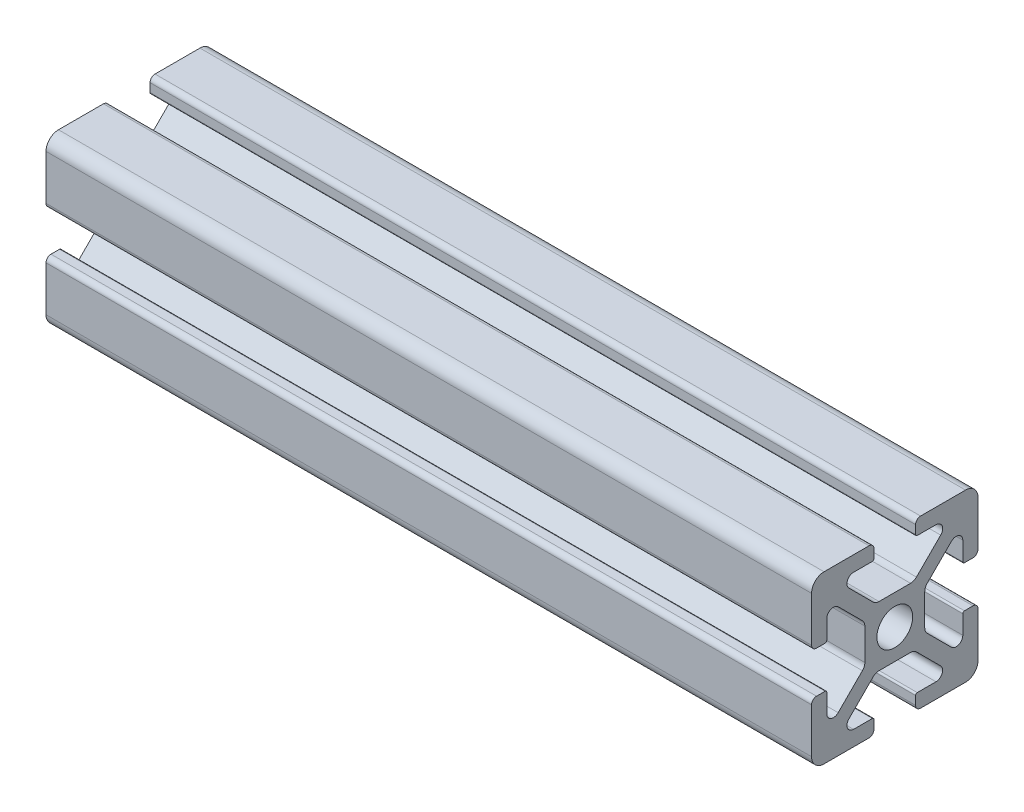
from build123d import *

# Parameters (mm, degrees)
BOSS_EXTRUDE1_DEPTH = 92


with BuildPart() as part:
    # Sketch3 → Boss-Extrude1 (new body)
    with BuildSketch(Plane(origin=(0, 0, 0), x_dir=(0, 0, -1), z_dir=(1, 0, 0))):
        with BuildLine():
            Line((-5.515685425, 6.807463915), (-2.601114729, 3.892893219))
            ThreePointArc((-2.601114729, 3.892893219), (-2.27669138, 3.676120467), (-1.894007948, 3.6))
            Line((-1.894007948, 3.6), (0, 3.6))
            Line((0, 3.6), (0, 2.15))
            ThreePointArc((0, 2.15), (-1.52027958, 1.52027958), (-2.15, 0))
            Line((-2.15, 0), (-3.6, 0))
            Line((-3.6, 0), (-3.6, 1.894007948))
            ThreePointArc((-3.6, 1.894007948), (-3.676120467, 2.27669138), (-3.892893219, 2.601114729))
            Line((-3.892893219, 2.601114729), (-6.807463915, 5.515685425))
            ThreePointArc((-6.807463915, 5.515685425), (-7.679296086, 5.689103626), (-8.17314934, 4.95))
            Line((-8.17314934, 4.95), (-8.17314934, 2.7))
            ThreePointArc((-8.17314934, 2.7), (-8.231727984, 2.558578644), (-8.37314934, 2.5))
            Line((-8.37314934, 2.5), (-9.4, 2.5))
            ThreePointArc((-9.4, 2.5), (-9.824264069, 2.675735931), (-10, 3.1))
            Line((-10, 3.1), (-10, 8.5))
            ThreePointArc((-10, 8.5), (-9.560660172, 9.560660172), (-8.5, 10))
            Line((-8.5, 10), (-3.1, 10))
            ThreePointArc((-3.1, 10), (-2.675735931, 9.824264069), (-2.5, 9.4))
            Line((-2.5, 9.4), (-2.5, 8.37314934))
            ThreePointArc((-2.5, 8.37314934), (-2.558578644, 8.231727984), (-2.7, 8.17314934))
            Line((-2.7, 8.17314934), (-4.95, 8.17314934))
            ThreePointArc((-4.95, 8.17314934), (-5.689103626, 7.679296086), (-5.515685425, 6.807463915))
        make_face()
    extrude(amount=-BOSS_EXTRUDE1_DEPTH)

    # Mirror1: part across plane


with BuildPart() as part_1:
    add(part.part)
    add(part.part.mirror(Plane.ZX))

    # Mirror2: part across plane


with BuildPart() as part_2:
    add(part_1.part)
    add(part_1.part.mirror(Plane.XY))


solid = part_2.part
